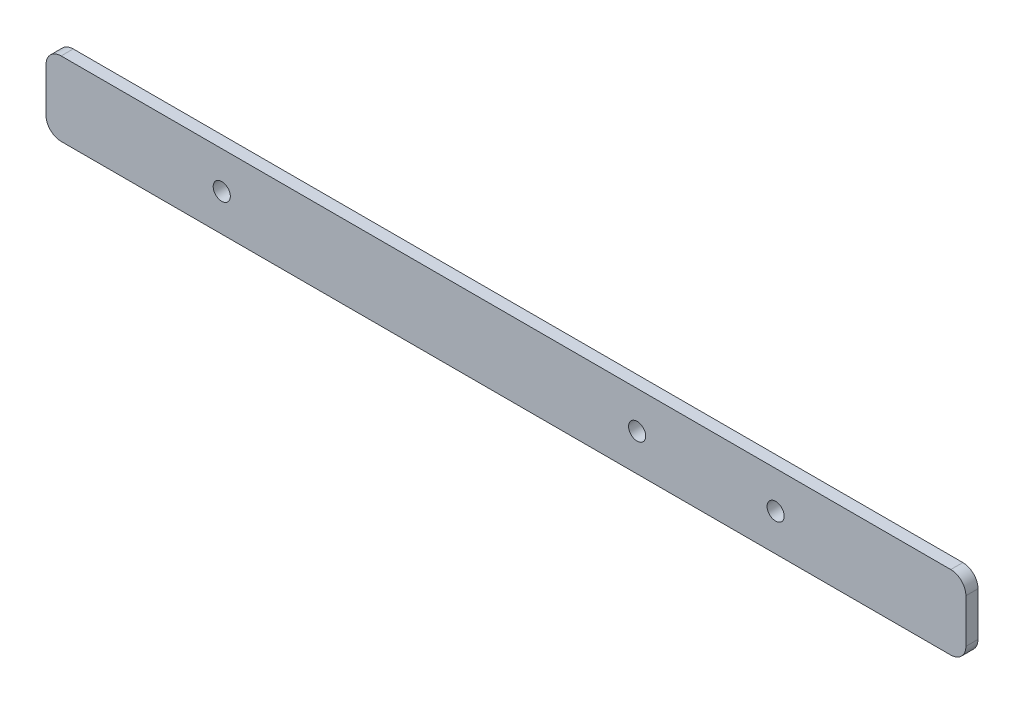
from build123d import *

# Parameters (mm, degrees)
SKETCH1_W             = 241.3
SKETCH1_H             = 19.431
BOSS_EXTRUDE1_DEPTH   = 3.175
F_8_CLEARANCE_HOLE1_D = 4.4958
FILLET1_R             = 3.96875


with BuildPart() as part:
    # Sketch1 → Boss-Extrude1 (new body)
    with BuildSketch(Plane.XY):
        with Locations((120.65, 9.7155)):
            Rectangle(SKETCH1_W, SKETCH1_H)
    extrude(amount=BOSS_EXTRUDE1_DEPTH)

    # #8 Clearance Hole1 (through all)
    with Locations(Plane.XY.offset(3.175)):
        with Locations((46.101, 9.7155), (155.067, 9.7155), (191.389, 9.7155)):
            Hole(F_8_CLEARANCE_HOLE1_D / 2)

    # Fillet1
    fillet1_edges = [part.edges().sort_by_distance(p)[0] for p in [
        (0, 19.431, 1.5875),
        (241.3, 19.431, 1.5875),
        (241.3, 0, 1.5875),
        (0, 0, 1.5875),
    ]]
    fillet(fillet1_edges, radius=FILLET1_R)


solid = part.part
